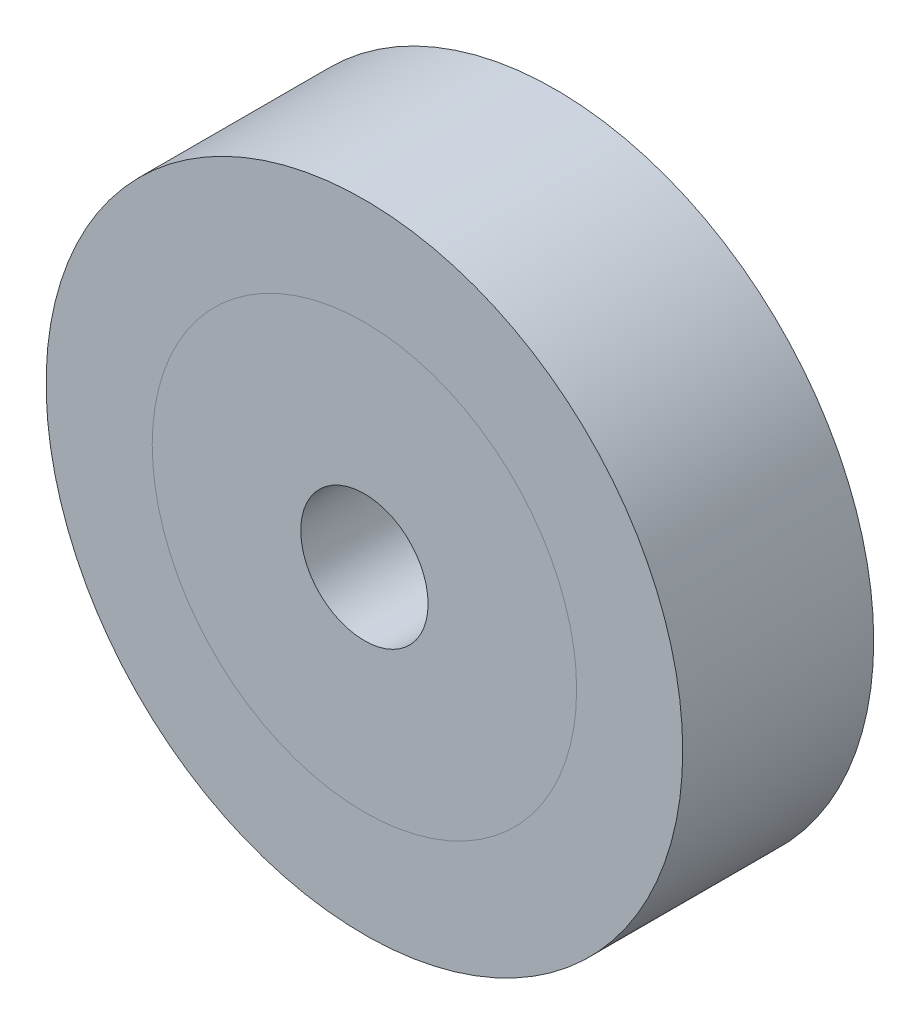
from build123d import *

# Parameters (mm, degrees)
SKETCH_1_R      = 15
SKETCH_1_R_2    = 3
EXTRUDE_1_DEPTH = 4.5


with BuildPart() as part:
    # 草图1 → 凸台-拉伸1 (new body, symmetric)
    with BuildSketch(Plane.XY):
        Circle(SKETCH_1_R)
        Circle(SKETCH_1_R_2, mode=Mode.SUBTRACT)
    extrude(amount=EXTRUDE_1_DEPTH, both=True)


solid = part.part
